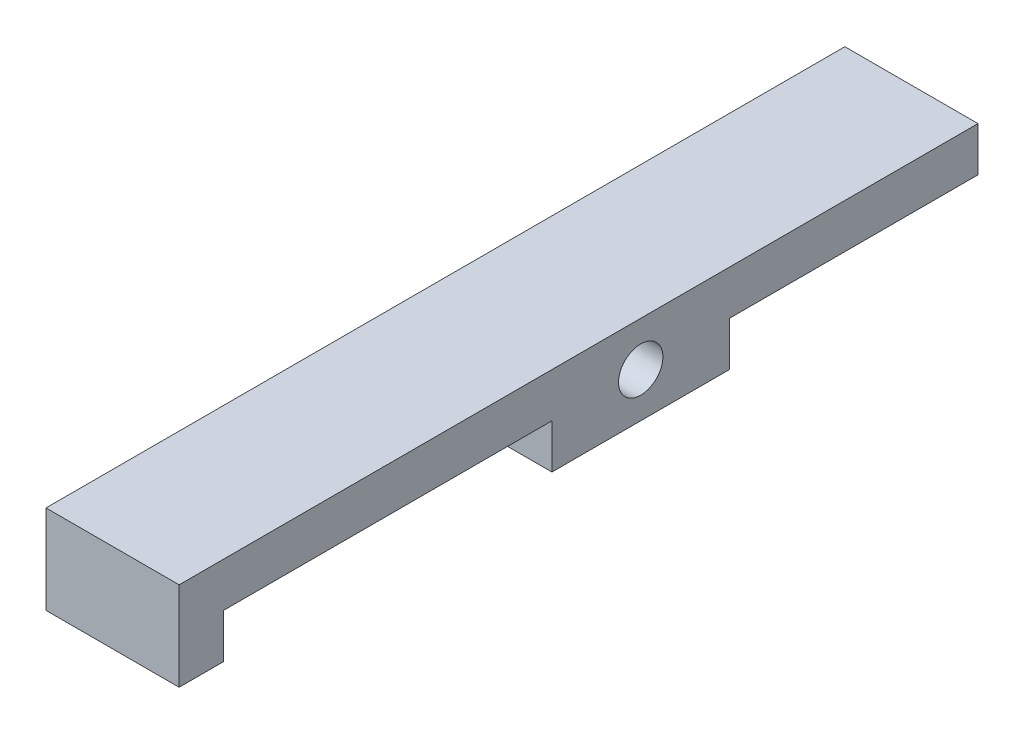
from build123d import *

# Parameters (mm, degrees)
SKETCH1_R           = 1.5875
BOSS_EXTRUDE1_DEPTH = 9.525


with BuildPart() as part:
    # Sketch1 → Boss-Extrude1 (new body)
    with BuildSketch(Plane(origin=(0, 0, 0), x_dir=(0, 0, -1), z_dir=(1, 0, 0))):
        Polygon((0, 1.5875), (0, -1.5875), (-17.78, -1.5875), (-17.78, -4.7625), (-30.48, -4.7625), (-30.48, -1.5875), (-53.975, -1.5875), (-53.975, -4.7625), (-57.15, -4.7625), (-57.15, 1.5875), align=None)
        with Locations((-24.13, -1.5875)):
            Circle(SKETCH1_R, mode=Mode.SUBTRACT)
    extrude(amount=BOSS_EXTRUDE1_DEPTH)


solid = part.part
